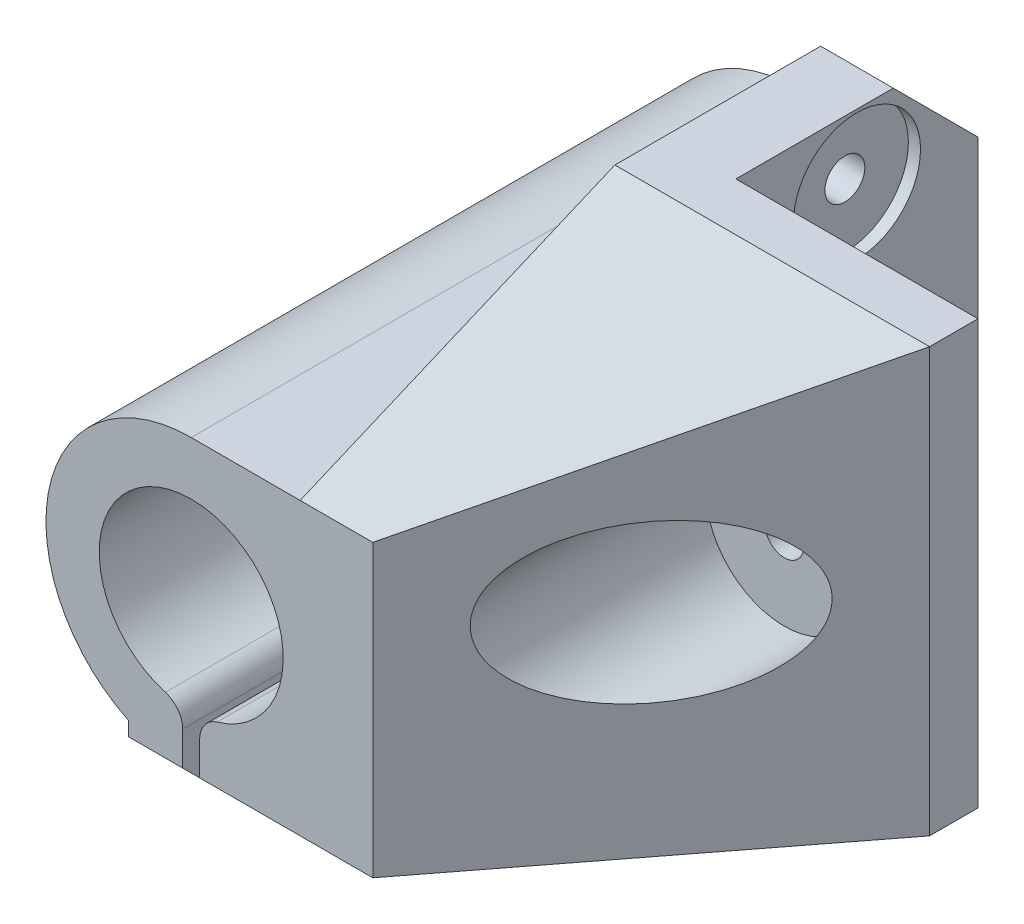
from build123d import *

# Parameters (mm, degrees)
ESBO_O1_R                  = 1.6
RESSALTO_EXTRUS_O1_DEPTH   = 50
ESBO_O2_W                  = 20
ESBO_O2_H                  = 20
CORTE_EXTRUS_O1_DEPTH      = 43
ESBO_O3_R                  = 1.65
CORTE_EXTRUS_O2_DEPTH      = 22
CORTE_EXTRUS_O2_DEPTH_BACK = 27
ESBO_O6_R                  = 1.65
CORTE_EXTRUS_O4_DEPTH      = 18.2
FILETE1_R                  = 2
ESBO_O4_R                  = 6.5
CORTE_EXTRUS_O5_DEPTH      = 24
CORTE_EXTRUS_O6_DEPTH      = 1
ESBO_O8_R                  = 5.25
CORTE_EXTRUS_O7_DEPTH      = 1
ESBO_O9_R                  = 5.25
CORTE_EXTRUS_O8_DEPTH      = 1


with BuildPart() as part:
    # Esboço1 → Ressalto-extrusão1 (new body)
    with BuildSketch(Plane.XY):
        with BuildLine():
            Line((0, 0), (0, 11))
            Line((0, 11), (-26, 11))
            Line((-26, 11), (-26, 0))
            Line((-26, 0), (-35, 0))
            ThreePointArc((-35, 0), (-46.699949915, -9.333321918), (-40.2, -22.814804668))
            Line((-40.2, -22.814804668), (-40.2, -31))
            Line((-40.2, -31), (-35.7, -31))
            Line((-35.7, -31), (-35.7, -19.567694497))
            ThreePointArc((-35.7, -19.567694497), (-35, -4.4), (-34.3, -19.567694497))
            Line((-34.3, -19.567694497), (-34.3, -31))
            Line((-34.3, -31), (-29.8, -31))
            Line((-29.8, -31), (-29.8, -24))
            Line((-29.8, -24), (0, -24))
            Line((0, -24), (0, 0))
        make_face()
        with Locations((-10, -6.5)):
            Circle(ESBO_O1_R, mode=Mode.SUBTRACT)
    extrude(amount=RESSALTO_EXTRUS_O1_DEPTH)

    # Esboço2 → Corte-extrusão1 (cut, through all)
    with BuildSketch(Plane(origin=(0, 11, 0), x_dir=(1, 0, 0), z_dir=(0, 1, 0))):
        Polygon((0, -24), (-20, -50), (0, -50), align=None)
        with Locations((-10, -10)):
            Rectangle(ESBO_O2_W, ESBO_O2_H)
    extrude(amount=-CORTE_EXTRUS_O1_DEPTH, mode=Mode.SUBTRACT)

    # Esboço3 → Corte-extrusão2 (cut, two sides)
    with BuildSketch(Plane.ZY.offset(26)) as corte_extrus_o2_sk:
        with Locations((10, 5.5)):
            Circle(ESBO_O3_R)
        Polygon((50, -24), (43, -31), (50, -31), align=None)
        Polygon((50, 0), (24, 11), (50, 11), align=None)
        Polygon((0, -24), (0, -31), (7, -31), align=None)
        Polygon((7, 11), (0, 4), (0, 11), align=None)
    extrude(amount=CORTE_EXTRUS_O2_DEPTH, mode=Mode.SUBTRACT)
    extrude(corte_extrus_o2_sk.sketch, amount=-CORTE_EXTRUS_O2_DEPTH_BACK, mode=Mode.SUBTRACT)

    # Esboço6 → Corte-extrusão4 (cut, through all)
    with BuildSketch(Plane(origin=(-29.8, 0, 0), x_dir=(0, 0, -1), z_dir=(1, 0, 0))):
        with Locations((-38, -27.5)):
            Circle(ESBO_O6_R)
        with Locations((-12, -27.5)):
            Circle(ESBO_O6_R)
    extrude(amount=-CORTE_EXTRUS_O4_DEPTH, mode=Mode.SUBTRACT)

    # Filete1
    filete1_edges = [part.edges().sort_by_distance(p)[0] for p in [
        (-34.3, -19.567694497, 25),
        (-35.7, -19.567694497, 25),
    ]]
    fillet(filete1_edges, radius=FILETE1_R)

    # Esboço4 → Corte-extrusão5 (cut)
    with BuildSketch(Plane.XY.offset(50)):
        with Locations((-10, -6.5)):
            Circle(ESBO_O4_R)
    extrude(amount=-CORTE_EXTRUS_O5_DEPTH, mode=Mode.SUBTRACT)

    # Esboço7 → Corte-extrusão6 (cut)
    with BuildSketch(Plane(origin=(-29.8, 0, 0), x_dir=(0, 0, -1), z_dir=(1, 0, 0))):
        Polygon((-8.824573519, -27.5), (-10.41228676, -24.75), (-13.58771324, -24.75), (-15.175426481, -27.5), (-13.58771324, -30.25), (-10.41228676, -30.25), align=None)
        Polygon((-34.824573519, -27.5), (-36.41228676, -24.75), (-39.58771324, -24.75), (-41.175426481, -27.5), (-39.58771324, -30.25), (-36.41228676, -30.25), align=None)
    extrude(amount=-CORTE_EXTRUS_O6_DEPTH, mode=Mode.SUBTRACT)

    # Esboço8 → Corte-extrusão7 (cut)
    with BuildSketch(Plane(origin=(-20, 0, 0), x_dir=(0, 0, -1), z_dir=(1, 0, 0))):
        with Locations((-10, 5.5)):
            Circle(ESBO_O8_R)
    extrude(amount=-CORTE_EXTRUS_O7_DEPTH, mode=Mode.SUBTRACT)

    # Esboço9 → Corte-extrusão8 (cut)
    with BuildSketch(Plane(origin=(0, 0, 20), x_dir=(-1, 0, 0), z_dir=(0, 0, -1))):
        with Locations((10, -6.5)):
            Circle(ESBO_O9_R)
    extrude(amount=-CORTE_EXTRUS_O8_DEPTH, mode=Mode.SUBTRACT)


solid = part.part
